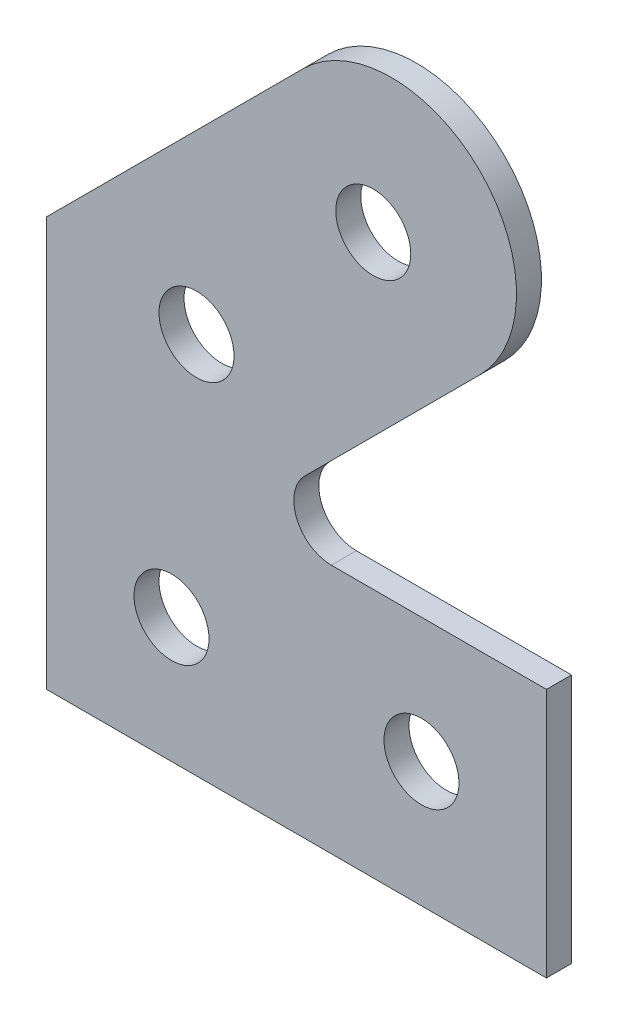
from build123d import *

# Parameters (mm, degrees)
ESQUISSE1_R        = 1.5
BOSS_EXTRU_1_DEPTH = 1


with BuildPart() as part:
    # Esquisse1 → Boss.-Extru.1 (new body)
    with BuildSketch(Plane.XY):
        with BuildLine():
            Line((0, 0), (20, 0))
            Line((20, 0), (20, 10))
            Line((20, 10), (11.392388155, 10))
            ThreePointArc((11.392388155, 10), (10.006568857, 10.925974851), (10.331727984, 12.560660172))
            Line((10.331727984, 12.560660172), (17.335533906, 19.564466094))
            ThreePointArc((17.335533906, 19.564466094), (17.335533906, 26.635533906), (10.264466094, 26.635533906))
            Line((10.264466094, 26.635533906), (0, 16.371067812))
            Line((0, 16.371067812), (0, 0))
        make_face()
        with Locations((5, 5)):
            Circle(ESQUISSE1_R, mode=Mode.SUBTRACT)
        with Locations((15, 5)):
            Circle(ESQUISSE1_R, mode=Mode.SUBTRACT)
        with Locations((6, 15.3)):
            Circle(ESQUISSE1_R, mode=Mode.SUBTRACT)
        with Locations((13.071067812, 22.371067812)):
            Circle(ESQUISSE1_R, mode=Mode.SUBTRACT)
    extrude(amount=BOSS_EXTRU_1_DEPTH)


solid = part.part
